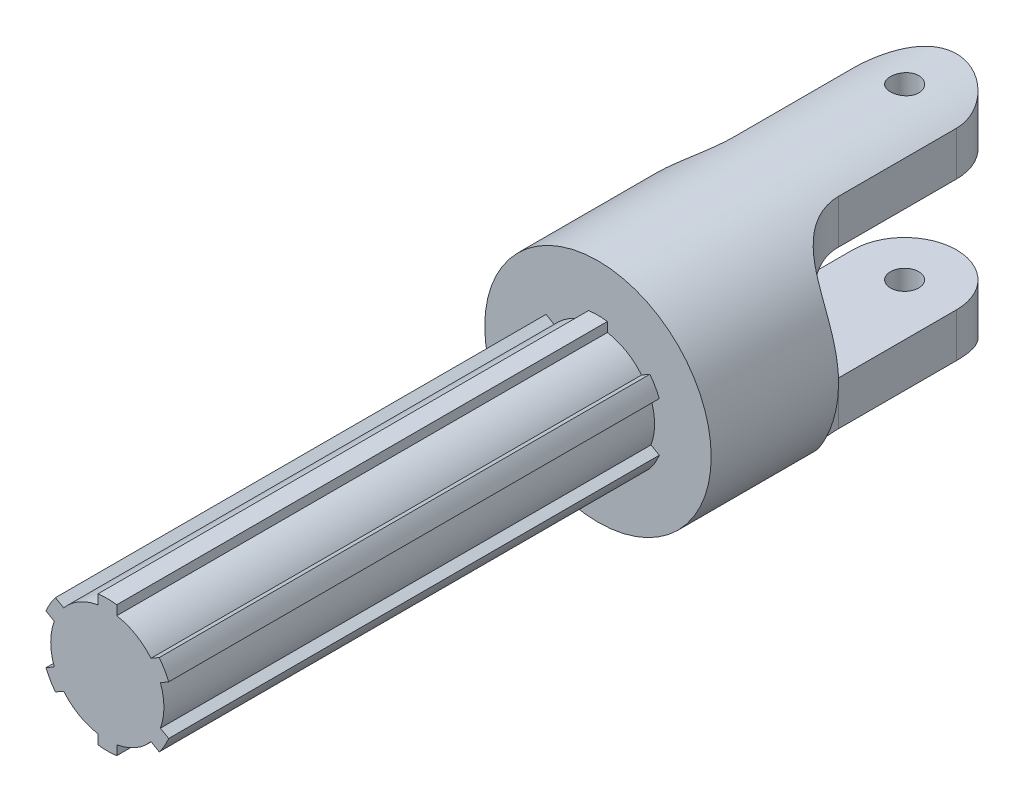
from build123d import *

# Parameters (mm, degrees)
SKETCH_1_R          = 6
SKETCH_1_R_2        = 2.5
EXTRUDE_1_DEPTH     = 19
SKETCH_2_OUTSIDE_W  = 19.096
SKETCH_2_OUTSIDE_H  = 26.096
SKETCH_2_OUTSIDE_R  = 0.75
CUT_EXTRUDE_1_DEPTH = 9.5
CUT_EXTRUDE_2_DEPTH = 9.5
EXTRUDE_2_DEPTH     = 31


with BuildPart() as part:
    # 草图1 → 凸台-拉伸1 (new body)
    with BuildSketch(Plane.XY):
        Circle(SKETCH_1_R)
        Circle(SKETCH_1_R_2, mode=Mode.SUBTRACT)
    extrude(amount=EXTRUDE_1_DEPTH)

    # 草图2 outside → 切除-拉伸1 (cut, symmetric)
    with BuildSketch(Plane(origin=(0, 0, 0), x_dir=(1, 0, 0), z_dir=(0, 1, 0))):
        with Locations((0, -9.5)):
            Rectangle(SKETCH_2_OUTSIDE_W, SKETCH_2_OUTSIDE_H)
        with BuildLine():
            Line((-2.75, -2.75), (-2.75, -9))
            ThreePointArc((-2.75, -9), (-3.701902961, -11.298097039), (-6, -12.25))
            Line((-6, -12.25), (-6, -19))
            Line((-6, -19), (6, -19))
            Line((6, -19), (6, -12.25))
            ThreePointArc((6, -12.25), (3.701902961, -11.298097039), (2.75, -9))
            Line((2.75, -9), (2.75, -2.75))
            ThreePointArc((2.75, -2.75), (0, 0), (-2.75, -2.75))
        make_face(mode=Mode.SUBTRACT)
        with Locations((0, -2.75)):
            Circle(SKETCH_2_OUTSIDE_R)
    extrude(amount=CUT_EXTRUDE_1_DEPTH, both=True, mode=Mode.SUBTRACT)

    # 草图3 → 切除-拉伸2 (cut, symmetric)
    with BuildSketch(Plane(origin=(0, 0, 0), x_dir=(0, 0, -1), z_dir=(1, 0, 0))):
        with BuildLine():
            Line((-9.250000001, 3), (0, 3))
            Line((0, 3), (0, -3))
            Line((0, -3), (-9.250000001, -3))
            ThreePointArc((-9.250000001, -3), (-12.250000001, 0), (-9.250000001, 3))
        make_face()
    extrude(amount=CUT_EXTRUDE_2_DEPTH, both=True, mode=Mode.SUBTRACT)

    # 草图5 → 凸台-拉伸2 (add)
    with BuildSketch(Plane(origin=(0, 0, 14), x_dir=(-1, 0, 0), z_dir=(0, 0, -1))):
        with BuildLine():
            Line((-0.5, 3.464101615), (-0.5, 2.958039892))
            ThreePointArc((-0.5, 2.958039892), (-1.5, 2.598076211), (-2.311737691, 1.912032648))
            Line((-2.311737691, 1.912032648), (-2.75, 2.165063509))
            ThreePointArc((-2.75, 2.165063509), (-3.031088913, 1.75), (-3.25, 1.299038106))
            Line((-3.25, 1.299038106), (-2.811737691, 1.046007244))
            ThreePointArc((-2.811737691, 1.046007244), (-3, 0), (-2.811737691, -1.046007244))
            Line((-2.811737691, -1.046007244), (-3.25, -1.299038106))
            ThreePointArc((-3.25, -1.299038106), (-3.031088913, -1.75), (-2.75, -2.165063509))
            Line((-2.75, -2.165063509), (-2.311737691, -1.912032648))
            ThreePointArc((-2.311737691, -1.912032648), (-1.5, -2.598076211), (-0.5, -2.958039892))
            Line((-0.5, -2.958039892), (-0.5, -3.464101615))
            ThreePointArc((-0.5, -3.464101615), (0, -3.5), (0.5, -3.464101615))
            Line((0.5, -3.464101615), (0.5, -2.958039892))
            ThreePointArc((0.5, -2.958039892), (1.5, -2.598076211), (2.311737691, -1.912032648))
            Line((2.311737691, -1.912032648), (2.75, -2.165063509))
            ThreePointArc((2.75, -2.165063509), (3.031088913, -1.75), (3.25, -1.299038106))
            Line((3.25, -1.299038106), (2.811737691, -1.046007244))
            ThreePointArc((2.811737691, -1.046007244), (3, 0), (2.811737691, 1.046007244))
            Line((2.811737691, 1.046007244), (3.25, 1.299038106))
            ThreePointArc((3.25, 1.299038106), (3.031088913, 1.75), (2.75, 2.165063509))
            Line((2.75, 2.165063509), (2.311737691, 1.912032648))
            ThreePointArc((2.311737691, 1.912032648), (1.5, 2.598076211), (0.5, 2.958039892))
            Line((0.5, 2.958039892), (0.5, 3.464101615))
            ThreePointArc((0.5, 3.464101615), (0, 3.5), (-0.5, 3.464101615))
        make_face()
    extrude(amount=-EXTRUDE_2_DEPTH)


solid = part.part
